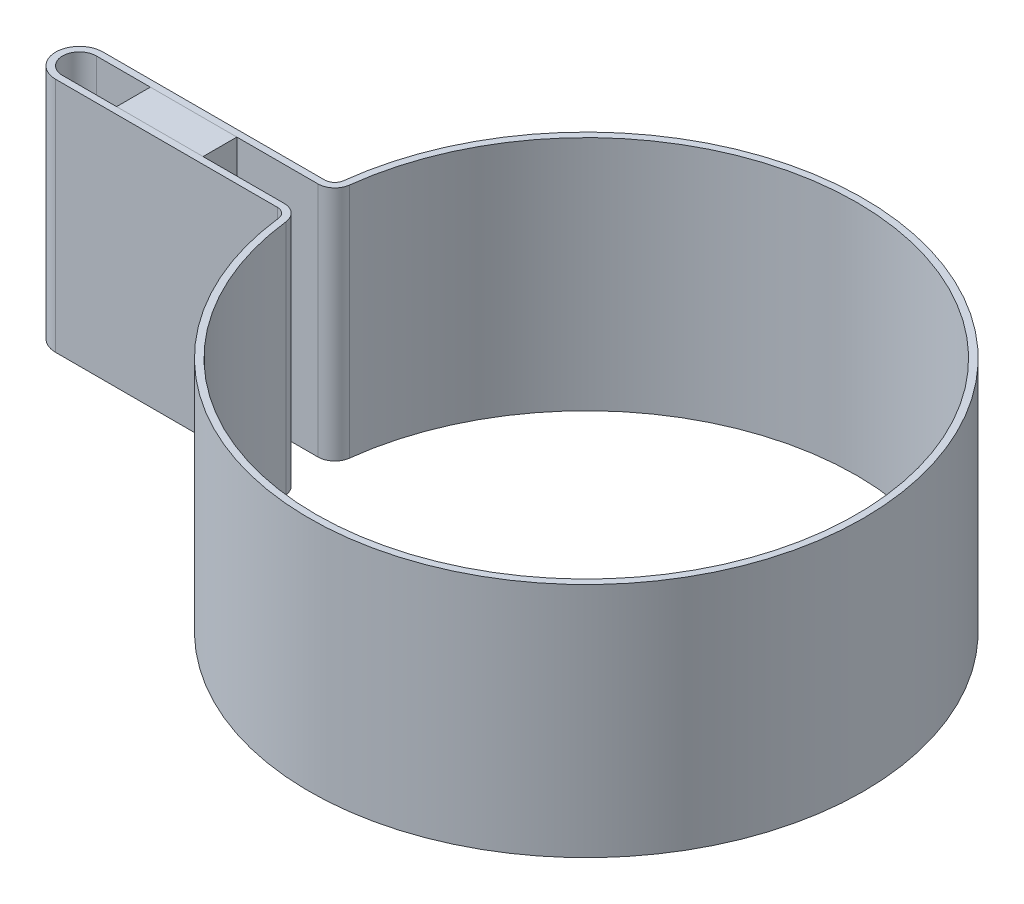
from build123d import *

# Parameters (mm, degrees)
BOSS_EXTRUDE1_DEPTH = 35
SKETCH2_W           = 12.79514246
SKETCH2_H           = 7
BOSS_EXTRUDE2_DEPTH = 35


with BuildPart() as part:
    # Sketch1 → Boss-Extrude1 (new body)
    with BuildSketch(Plane(origin=(0, 0, 0), x_dir=(1, 0, 0), z_dir=(0, 1, 0))):
        with BuildLine():
            Line((-75, 3.5), (-42.20485754, 3.5))
            ThreePointArc((-42.20485754, 3.5), (-41.208540794, 3.878682498), (-40.715274333, 4.823529412))
            ThreePointArc((-40.715274333, 4.823529412), (41, 0), (-40.715274333, -4.823529412))
            ThreePointArc((-40.715274333, -4.823529412), (-41.208540794, -3.878682498), (-42.20485754, -3.5))
            Line((-42.20485754, -3.5), (-75, -3.5))
            ThreePointArc((-75, -3.5), (-78.5, 0), (-75, 3.5))
        make_face()
        with BuildLine():
            Line((-75, 2.5), (-42.20485754, 2.5))
            ThreePointArc((-42.20485754, 2.5), (-40.54432963, 3.131137496), (-39.722218861, 4.705882353))
            ThreePointArc((-39.722218861, 4.705882353), (40, 0), (-39.722218861, -4.705882353))
            ThreePointArc((-39.722218861, -4.705882353), (-40.54432963, -3.131137496), (-42.20485754, -2.5))
            Line((-42.20485754, -2.5), (-75, -2.5))
            ThreePointArc((-75, -2.5), (-77.5, 0), (-75, 2.5))
        make_face(mode=Mode.SUBTRACT)
    extrude(amount=BOSS_EXTRUDE1_DEPTH)


with BuildPart() as body_2:
    # Sketch2 → Boss-Extrude2 (new body)
    with BuildSketch(Plane(origin=(0, 35, 0), x_dir=(1, 0, 0), z_dir=(0, 1, 0))):
        with Locations((-60.60242877, 0)):
            Rectangle(SKETCH2_W, SKETCH2_H)
    extrude(amount=-BOSS_EXTRUDE2_DEPTH)


solid = Compound([part.part, body_2.part])
